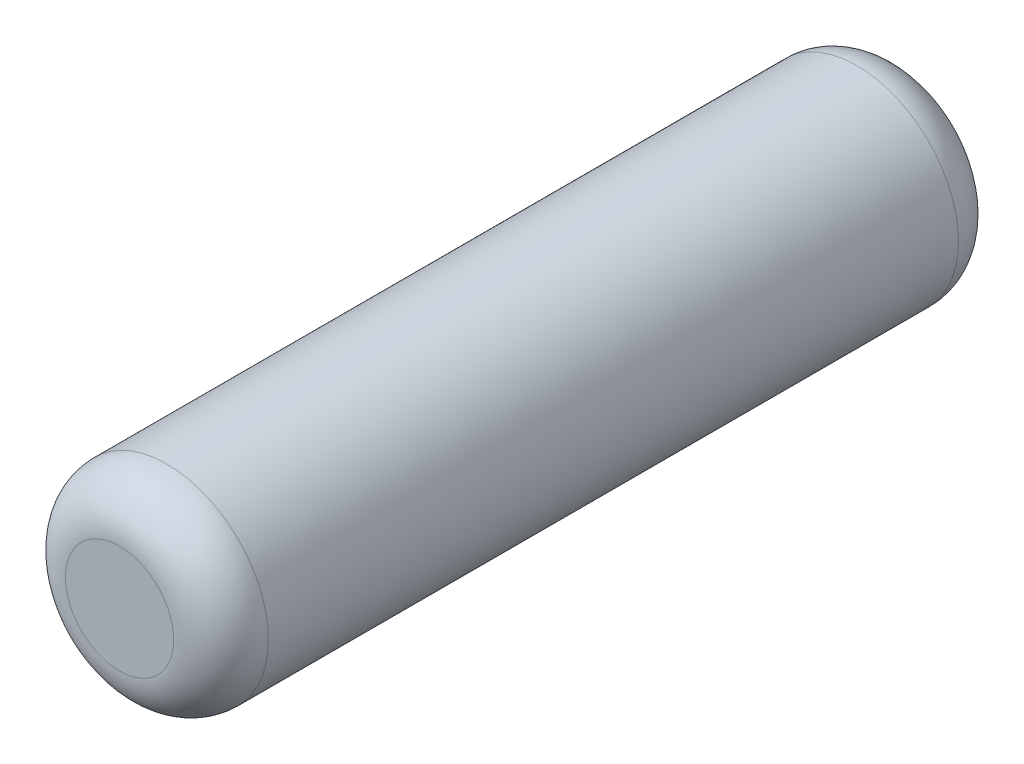
from build123d import *

# Parameters (mm, degrees)
SKETCH1_R           = 0.75
BOSS_EXTRUDE1_DEPTH = 2.9
FILLET1_R           = 0.35


with BuildPart() as part:
    # Sketch1 → Boss-Extrude1 (new body, symmetric)
    with BuildSketch(Plane.XY):
        Circle(SKETCH1_R)
    extrude(amount=BOSS_EXTRUDE1_DEPTH, both=True)

    # Fillet1
    fillet1_edges = [part.edges().sort_by_distance(p)[0] for p in [
        (-0.75, 0, -2.9),
        (-0.75, 0, 2.9),
    ]]
    fillet(fillet1_edges, radius=FILLET1_R)


solid = part.part
